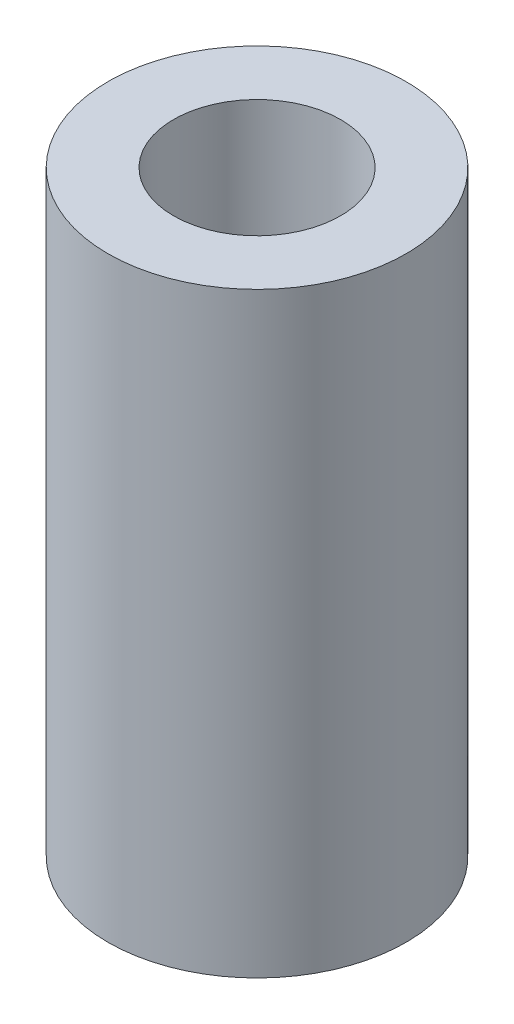
from build123d import *

# Parameters (mm, degrees)
SKETCH1_R           = 2.5
SKETCH1_R_2         = 1.4
BOSS_EXTRUDE1_DEPTH = 10


with BuildPart() as part:
    # Sketch1 → Boss-Extrude1 (new body)
    with BuildSketch(Plane(origin=(0, 0, 0), x_dir=(1, 0, 0), z_dir=(0, 1, 0))):
        Circle(SKETCH1_R)
        Circle(SKETCH1_R_2, mode=Mode.SUBTRACT)
    extrude(amount=BOSS_EXTRUDE1_DEPTH)


solid = part.part
